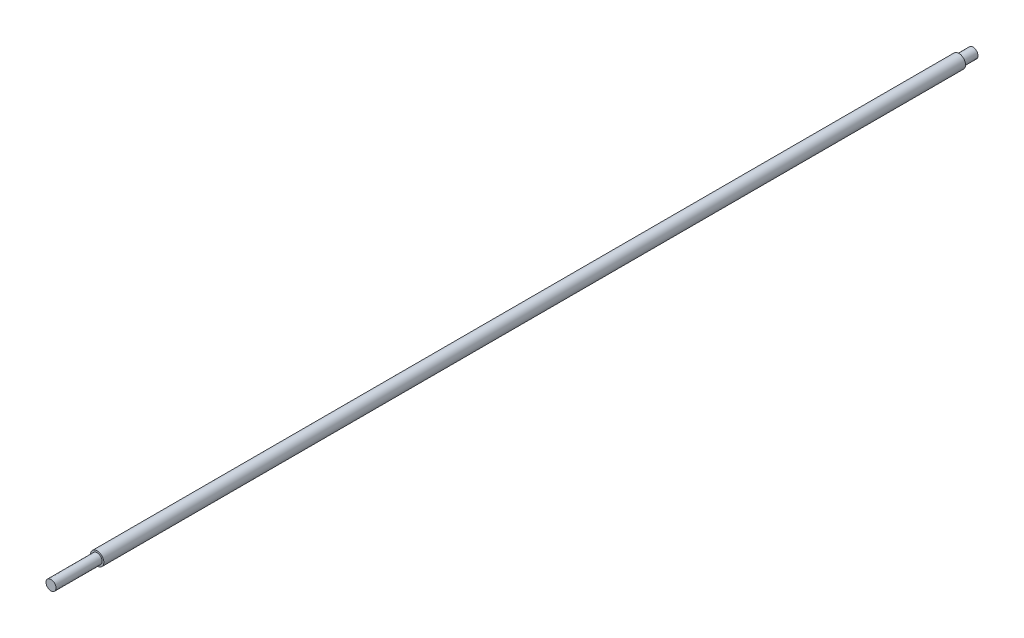
from build123d import *

# Parameters (mm, degrees)
SKETCH1_R          = 8
EXTRUDE1_DEPTH     = 1102
SKETCH3_R          = 8
SKETCH3_R_2        = 6
CUT_EXTRUDE1_DEPTH = 54
SKETCH4_R          = 8
SKETCH4_R_2        = 6
CUT_EXTRUDE2_DEPTH = 20
SKETCH5_R          = 6
EXTRUDE2_DEPTH     = 4.4
SKETCH6_R          = 8
SKETCH6_R_2        = 6
EXTRUDE3_DEPTH     = 3
SKETCH7_R          = 8
SKETCH7_R_2        = 6
EXTRUDE4_DEPTH     = 3


with BuildPart() as part:
    # Sketch1 → Extrude1 (new body)
    with BuildSketch(Plane.XY):
        Circle(SKETCH1_R)
    extrude(amount=EXTRUDE1_DEPTH)

    # Sketch3 → Cut-Extrude1 (cut)
    with BuildSketch(Plane.XY.offset(1102)):
        Circle(SKETCH3_R)
        Circle(SKETCH3_R_2, mode=Mode.SUBTRACT)
    extrude(amount=-CUT_EXTRUDE1_DEPTH, mode=Mode.SUBTRACT)

    # Sketch4 → Cut-Extrude2 (cut)
    with BuildSketch(Plane(origin=(0, 0, 0), x_dir=(-1, 0, 0), z_dir=(0, 0, -1))):
        Circle(SKETCH4_R)
        Circle(SKETCH4_R_2, mode=Mode.SUBTRACT)
    extrude(amount=-CUT_EXTRUDE2_DEPTH, mode=Mode.SUBTRACT)

    # Sketch5 → Extrude2 (add)
    with BuildSketch(Plane.XY.offset(1102)):
        Circle(SKETCH5_R)
    extrude(amount=EXTRUDE2_DEPTH)

    # Sketch6 → Extrude3 (add)
    with BuildSketch(Plane.XY.offset(1048)):
        Circle(SKETCH6_R)
        Circle(SKETCH6_R_2, mode=Mode.SUBTRACT)
    extrude(amount=EXTRUDE3_DEPTH)

    # Sketch7 → Extrude4 (add)
    with BuildSketch(Plane(origin=(0, 0, 20), x_dir=(-1, 0, 0), z_dir=(0, 0, -1))):
        Circle(SKETCH7_R)
        Circle(SKETCH7_R_2, mode=Mode.SUBTRACT)
    extrude(amount=EXTRUDE4_DEPTH)


solid = part.part
